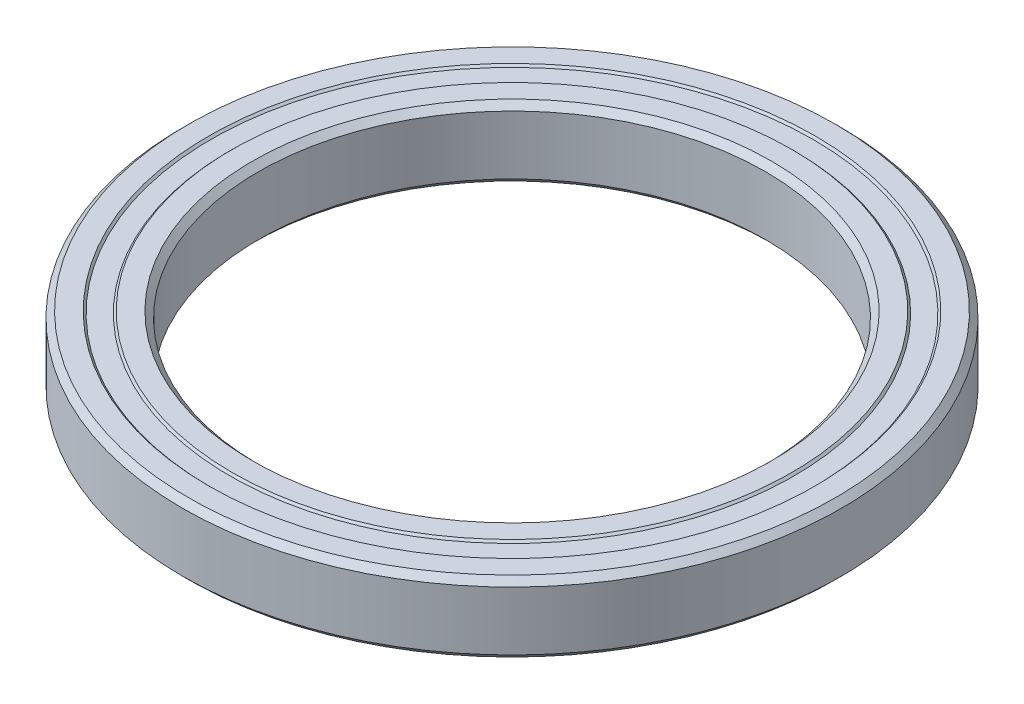
from build123d import *


with BuildPart() as part:
    # Sketch1 → Revolve1 (revolve)
    with BuildSketch(Plane.XY):
        Polygon((25, 2.9), (25, -2.9), (25.6, -3.5), (27.6, -3.5), (27.8, -3.3), (29.7, -3.3), (29.9, -3.5), (31.9, -3.5), (32.5, -2.9), (32.5, 2.9), (31.9, 3.5), (29.9, 3.5), (29.7, 3.3), (27.8, 3.3), (27.6, 3.5), (25.6, 3.5), align=None)
    revolve(axis=Axis((0, -1.349421972, 0), (0, 1, 0)))


solid = part.part
